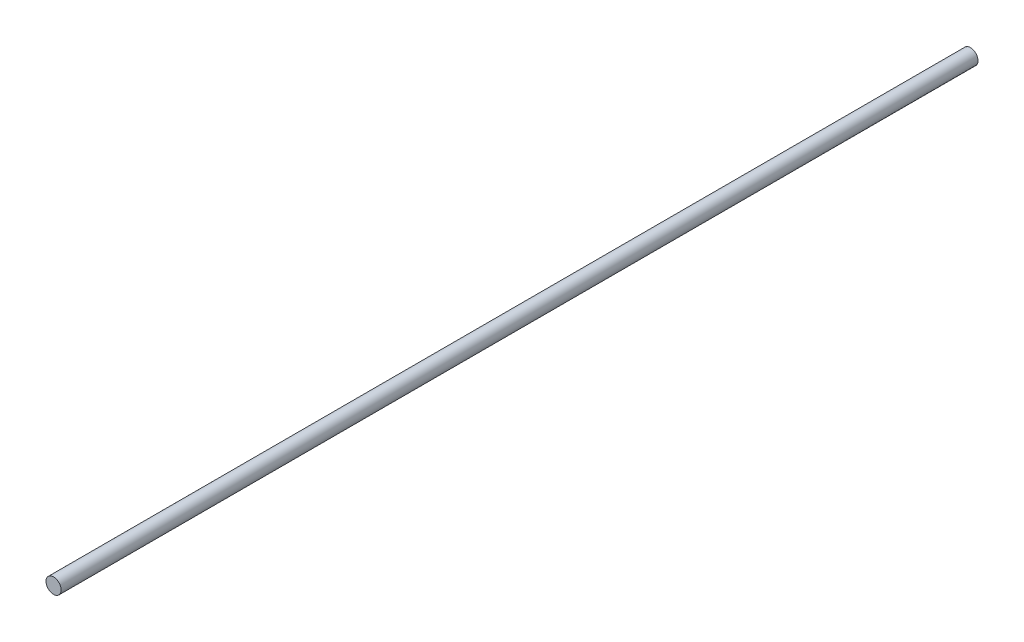
from build123d import *

# Parameters (mm, degrees)
ESBO_O1_R                = 3.97
RESSALTO_EXTRUS_O1_DEPTH = 240


with BuildPart() as part:
    # Esboço1 → Ressalto-extrusão1 (new body, symmetric)
    with BuildSketch(Plane.XY):
        Circle(ESBO_O1_R)
    extrude(amount=RESSALTO_EXTRUS_O1_DEPTH, both=True)


solid = part.part
